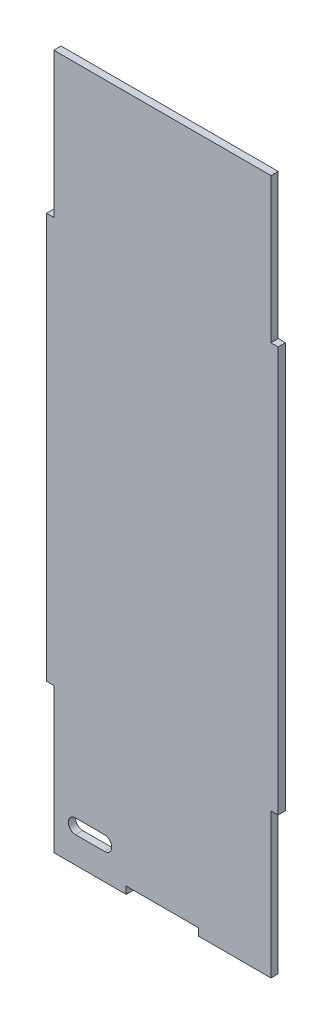
from build123d import *

# Parameters (mm, degrees)
SKETCH1_W                = 228.6
SKETCH1_H                = 609.6
BOSS_EXTRUDE1_DEPTH      = 6.35
CUT_EXTRUDE1_DEPTH       = 6.35
CUT_EXTRUDE4_DEPTH       = 1
CUT_EXTRUDE4_DEPTH_BACK  = 7.35
CUT_EXTRUDE7_DEPTH       = 1
CUT_EXTRUDE7_DEPTH_BACK  = 7.35
CUT_EXTRUDE8_DEPTH       = 1
CUT_EXTRUDE8_DEPTH_BACK  = 7.35
CUT_EXTRUDE9_DEPTH       = 1
CUT_EXTRUDE9_DEPTH_BACK  = 7.35
CUT_EXTRUDE10_DEPTH      = 1
CUT_EXTRUDE10_DEPTH_BACK = 7.35
CUT_EXTRUDE11_DEPTH      = 1
CUT_EXTRUDE11_DEPTH_BACK = 7.35
CUT_EXTRUDE12_DEPTH      = 1
CUT_EXTRUDE12_DEPTH_BACK = 7.35


with BuildPart() as part:
    # Sketch1 → Boss-Extrude1 (new body)
    with BuildSketch(Plane.XY):
        with Locations((-114.3, 304.8)):
            Rectangle(SKETCH1_W, SKETCH1_H)
    extrude(amount=BOSS_EXTRUDE1_DEPTH)

    # Sketch2 → Cut-Extrude1 (cut)
    with BuildSketch(Plane.XY.offset(6.35)):
        with BuildLine():
            Line((-165.095373919, 23.135327723), (-190.495373919, 23.135327723))
            ThreePointArc((-190.495373919, 23.135327723), (-196.845373919, 29.485327723), (-190.495373919, 35.835327723))
            Line((-190.495373919, 35.835327723), (-165.095373919, 35.835327723))
            ThreePointArc((-165.095373919, 35.835327723), (-158.745373919, 29.485327723), (-165.095373919, 23.135327723))
        make_face()
    extrude(amount=-CUT_EXTRUDE1_DEPTH, mode=Mode.SUBTRACT)

    # Sketch6 → Cut-Extrude4 (cut, two sides)
    with BuildSketch(Plane.XY.offset(6.35)) as cut_extrude4_sk:
        Polygon((-19.05, -1299.222032855), (-19.05, 0), (-19.05, 127), (0, 127), (1299.222032855, 127), (3207.394059988, -1636.743484042), (1889.122027132, -3062.965516897), align=None)
    extrude(amount=CUT_EXTRUDE4_DEPTH, mode=Mode.SUBTRACT)
    extrude(cut_extrude4_sk.sketch, amount=-CUT_EXTRUDE4_DEPTH_BACK, mode=Mode.SUBTRACT)

    # Sketch5 → Cut-Extrude7 (cut, two sides)
    with BuildSketch(Plane.XY.offset(6.35)) as cut_extrude7_sk:
        Polygon((-19.05, 1908.822032855), (-19.05, 609.6), (-19.05, 482.6), (0, 482.6), (1299.222032855, 482.6), (3207.394059988, 2246.343484042), (1889.122027132, 3672.565516897), align=None)
    extrude(amount=CUT_EXTRUDE7_DEPTH, mode=Mode.SUBTRACT)
    extrude(cut_extrude7_sk.sketch, amount=-CUT_EXTRUDE7_DEPTH_BACK, mode=Mode.SUBTRACT)

    # Sketch11 → Cut-Extrude8 (cut, two sides)
    with BuildSketch(Plane.XY.offset(6.35)) as cut_extrude8_sk:
        Polygon((-12.7, 1549.984641462), (-12.7, 482.6), (-12.7, 127), (-12.7, -940.384641462), (2122.069282924, -940.384641462), (2122.069282924, 1549.984641462), align=None)
    extrude(amount=CUT_EXTRUDE8_DEPTH, mode=Mode.SUBTRACT)
    extrude(cut_extrude8_sk.sketch, amount=-CUT_EXTRUDE8_DEPTH_BACK, mode=Mode.SUBTRACT)

    # Sketch15 → Cut-Extrude9 (cut, two sides)
    with BuildSketch(Plane.XY.offset(6.35)) as cut_extrude9_sk:
        Polygon((-209.55, -1291.190200556), (-209.55, 0), (-209.55, 127), (-228.6, 127), (-1519.790200556, 127), (-3416.571079884, -1625.401447117), (-2106.330879328, -3043.591647673), align=None)
    extrude(amount=CUT_EXTRUDE9_DEPTH, mode=Mode.SUBTRACT)
    extrude(cut_extrude9_sk.sketch, amount=-CUT_EXTRUDE9_DEPTH_BACK, mode=Mode.SUBTRACT)

    # Sketch12 → Cut-Extrude10 (cut, two sides)
    with BuildSketch(Plane.XY.offset(6.35)) as cut_extrude10_sk:
        Polygon((-209.55, 1900.790200556), (-209.55, 609.6), (-209.55, 482.6), (-228.6, 482.6), (-1519.790200556, 482.6), (-3416.571079884, 2235.001447117), (-2106.330879328, 3653.191647673), align=None)
    extrude(amount=CUT_EXTRUDE10_DEPTH, mode=Mode.SUBTRACT)
    extrude(cut_extrude10_sk.sketch, amount=-CUT_EXTRUDE10_DEPTH_BACK, mode=Mode.SUBTRACT)

    # Sketch16 → Cut-Extrude11 (cut, two sides)
    with BuildSketch(Plane.XY.offset(6.35)) as cut_extrude11_sk:
        Polygon((-215.9, 1539.868828907), (-215.9, 482.6), (-215.9, 127), (-215.9, -930.268828907), (-2330.437657814, -930.268828907), (-2330.437657814, 1539.868828907), align=None)
    extrude(amount=CUT_EXTRUDE11_DEPTH, mode=Mode.SUBTRACT)
    extrude(cut_extrude11_sk.sketch, amount=-CUT_EXTRUDE11_DEPTH_BACK, mode=Mode.SUBTRACT)

    # Sketch18 → Cut-Extrude12 (cut, two sides)
    with BuildSketch(Plane.XY.offset(6.35)) as cut_extrude12_sk:
        Polygon((-82.55, -1258.029458787), (-82.55, 0), (-82.55, 6.35), (-146.05, 6.35), (-146.05, 0), (-146.05, -1258.029458787), (-146.05, -3774.088376361), (-82.55, -3774.088376361), align=None)
    extrude(amount=CUT_EXTRUDE12_DEPTH, mode=Mode.SUBTRACT)
    extrude(cut_extrude12_sk.sketch, amount=-CUT_EXTRUDE12_DEPTH_BACK, mode=Mode.SUBTRACT)


solid = part.part
